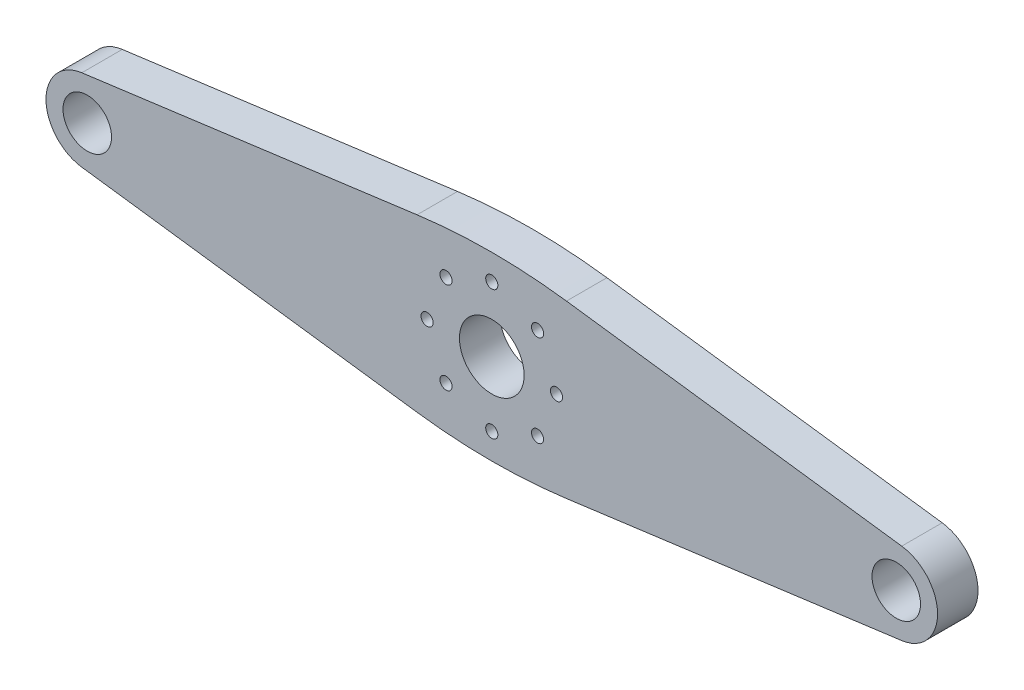
from build123d import *

# Parameters (mm, degrees)
SZKIC1_R                    = 4
SZKIC1_R_2                  = 0.75
SZKIC1_R_3                  = 3
DODANIE_WYCI_GNI_CIE1_DEPTH = 5


with BuildPart() as part:
    # Szkic1 → Dodanie-wyciągnięcie1 (new body)
    with BuildSketch(Plane.XY):
        with BuildLine():
            Line((-50.67287635, 5.055665151), (-9.235111676, 10.570763761))
            ThreePointArc((-9.235111676, 10.570763761), (0, 11.182632843), (9.235111676, 10.570763761))
            Line((9.235111676, 10.570763761), (50.67287635, 5.055665151))
            ThreePointArc((50.67287635, 5.055665151), (55.100246338, 0), (50.67287635, -5.055665151))
            Line((50.67287635, -5.055665151), (9.235111676, -10.570763761))
            ThreePointArc((9.235111676, -10.570763761), (0, -11.182632843), (-9.235111676, -10.570763761))
            Line((-9.235111676, -10.570763761), (-50.67287635, -5.055665151))
            ThreePointArc((-50.67287635, -5.055665151), (-55.100246338, 0), (-50.67287635, 5.055665151))
        make_face()
        Circle(SZKIC1_R, mode=Mode.SUBTRACT)
        with Locations((-5.656854249, 5.656854249)):
            Circle(SZKIC1_R_2, mode=Mode.SUBTRACT)
        with Locations((-8, 0)):
            Circle(SZKIC1_R_2, mode=Mode.SUBTRACT)
        with Locations((0, 8)):
            Circle(SZKIC1_R_2, mode=Mode.SUBTRACT)
        with Locations((5.656854249, 5.656854249)):
            Circle(SZKIC1_R_2, mode=Mode.SUBTRACT)
        with Locations((-50, 0)):
            Circle(SZKIC1_R_3, mode=Mode.SUBTRACT)
        with Locations((50, 0)):
            Circle(SZKIC1_R_3, mode=Mode.SUBTRACT)
        with Locations((8, 0)):
            Circle(SZKIC1_R_2, mode=Mode.SUBTRACT)
        with Locations((5.656854249, -5.656854249)):
            Circle(SZKIC1_R_2, mode=Mode.SUBTRACT)
        with Locations((0, -8)):
            Circle(SZKIC1_R_2, mode=Mode.SUBTRACT)
        with Locations((-5.656854249, -5.656854249)):
            Circle(SZKIC1_R_2, mode=Mode.SUBTRACT)
    extrude(amount=DODANIE_WYCI_GNI_CIE1_DEPTH)


solid = part.part
